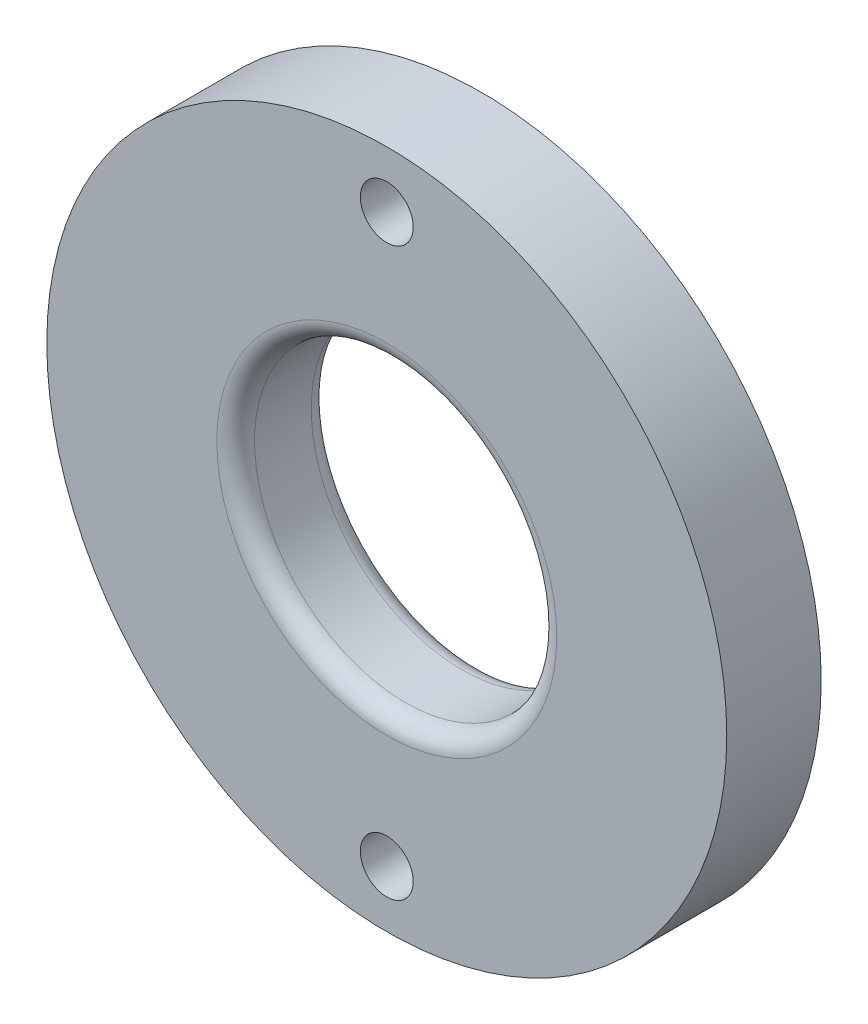
from build123d import *

# Parameters (mm, degrees)
SKETCH1_R             = 11.43
SKETCH1_R_2           = 5.08
BOSS_EXTRUDE1_DEPTH   = 3.175
FILLET1_R             = 0.635
F_2_56_TAPPED_HOLE1_D = 1.778


with BuildPart() as part:
    # Sketch1 → Boss-Extrude1 (new body)
    with BuildSketch(Plane.XY):
        Circle(SKETCH1_R)
        Circle(SKETCH1_R_2, mode=Mode.SUBTRACT)
    extrude(amount=BOSS_EXTRUDE1_DEPTH)

    # Fillet1
    fillet1_edges = [part.edges().sort_by_distance(p)[0] for p in [
        (-5.08, 0, 0),
        (-5.08, 0, 3.175),
    ]]
    fillet(fillet1_edges, radius=FILLET1_R)

    # #2-56 Tapped Hole1 (through all)
    with Locations(Plane.XY.offset(3.175)):
        with Locations((0, 9.525)):
            f_2_56_tapped_hole1 = Hole(F_2_56_TAPPED_HOLE1_D / 2)

    # Mirror1: #2-56 Tapped Hole1 across plane
    add(f_2_56_tapped_hole1.mirror(Plane.ZX), mode=Mode.SUBTRACT)


solid = part.part
